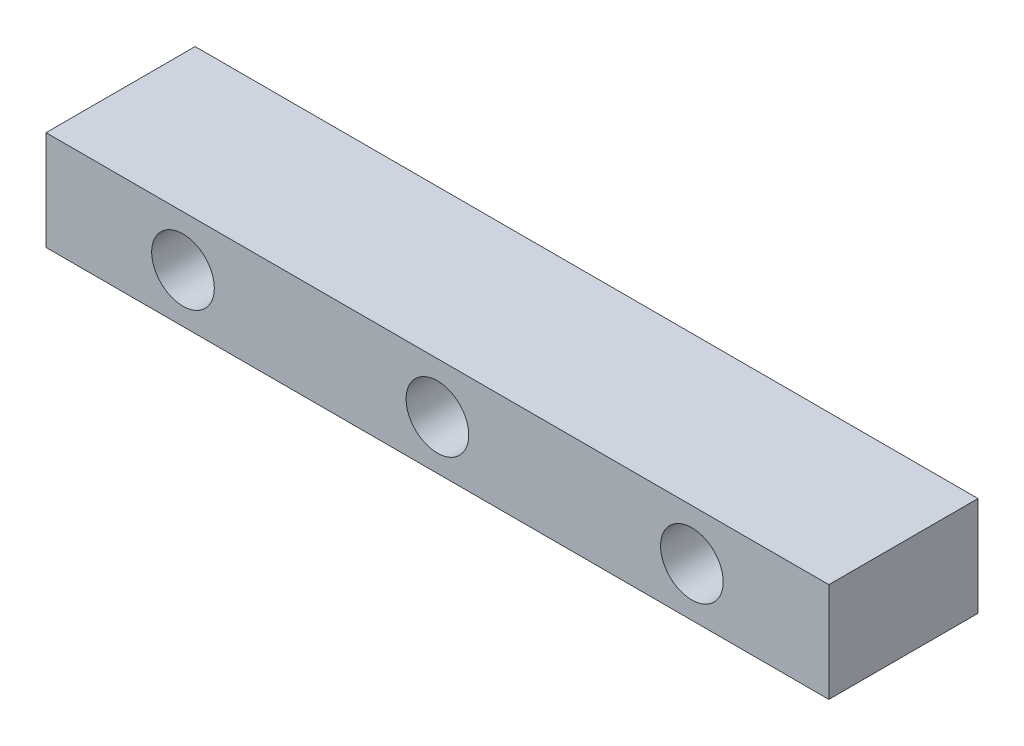
from build123d import *

# Parameters (mm, degrees)
SKETCH1_W           = 400
SKETCH1_H           = 76.2
BOSS_EXTRUDE1_DEPTH = 50.8
SKETCH2_R           = 16
CUT_EXTRUDE1_DEPTH  = 76.2


with BuildPart() as part:
    # Sketch1 → Boss-Extrude1 (new body)
    with BuildSketch(Plane(origin=(0, 0, 0), x_dir=(1, 0, 0), z_dir=(0, 1, 0))):
        with Locations((200, 38.1)):
            Rectangle(SKETCH1_W, SKETCH1_H)
    extrude(amount=BOSS_EXTRUDE1_DEPTH)

    # Sketch2 → Cut-Extrude1 (cut)
    with BuildSketch(Plane.XY):
        with Locations((70, 25)):
            Circle(SKETCH2_R)
        with Locations((200, 25)):
            Circle(SKETCH2_R)
        with Locations((330, 25)):
            Circle(SKETCH2_R)
    extrude(amount=-CUT_EXTRUDE1_DEPTH, mode=Mode.SUBTRACT)


solid = part.part
